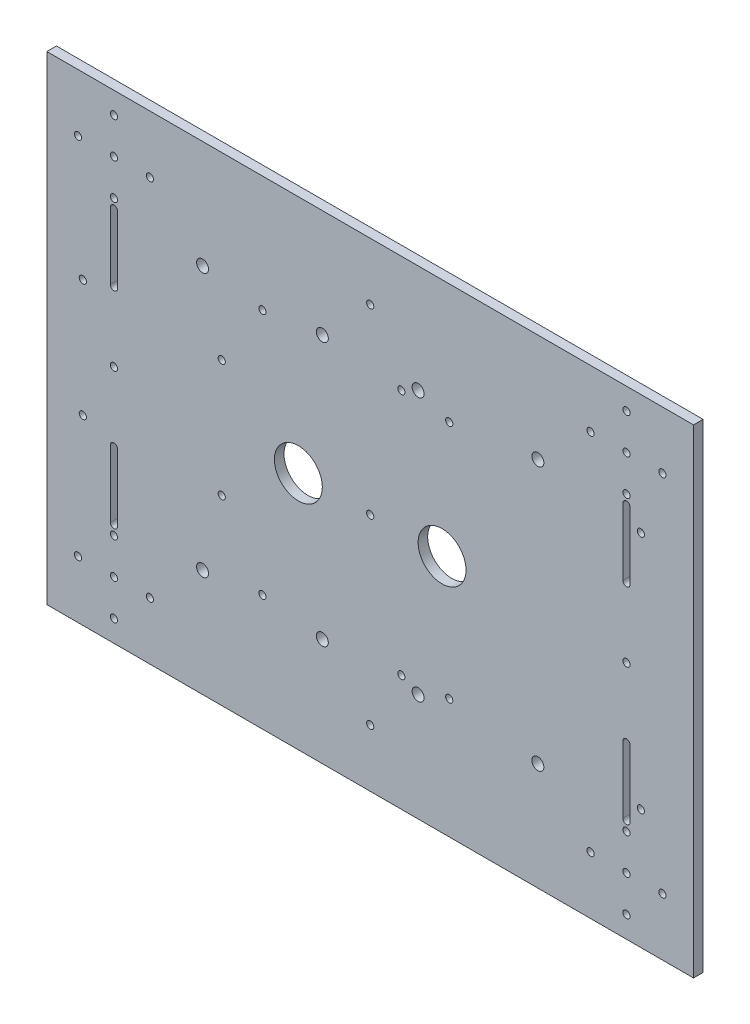
from build123d import *

# Parameters (mm, degrees)
SKETCH1_W           = 270
SKETCH1_H           = 200
SKETCH1_R           = 1.5
SKETCH1_R_2         = 10
SKETCH1_R_3         = 2.5
BOSS_EXTRUDE1_DEPTH = 4


with BuildPart() as part:
    # Sketch1 → Boss-Extrude1 (new body)
    with BuildSketch(Plane.XY):
        with Locations((74.901502586, -16.133333333)):
            Rectangle(SKETCH1_W, SKETCH1_H)
        with Locations((-32.098497414, -92.133333333)):
            Circle(SKETCH1_R, mode=Mode.SUBTRACT)
        with Locations((-17.098497414, -92.133333333)):
            Circle(SKETCH1_R, mode=Mode.SUBTRACT)
        with Locations((-32.098497414, -107.133333333)):
            Circle(SKETCH1_R, mode=Mode.SUBTRACT)
        with Locations((-47.098497414, -92.133333333)):
            Circle(SKETCH1_R, mode=Mode.SUBTRACT)
        with Locations((-32.098497414, -77.133333333)):
            Circle(SKETCH1_R, mode=Mode.SUBTRACT)
        with Locations((74.901502586, -16.133333333)):
            Circle(SKETCH1_R, mode=Mode.SUBTRACT)
        with Locations((196.901502586, -92.133333333)):
            Circle(SKETCH1_R, mode=Mode.SUBTRACT)
        with Locations((181.901502586, -77.133333333)):
            Circle(SKETCH1_R, mode=Mode.SUBTRACT)
        with Locations((181.901502586, -92.133333333)):
            Circle(SKETCH1_R, mode=Mode.SUBTRACT)
        with Locations((181.901502586, -107.133333333)):
            Circle(SKETCH1_R, mode=Mode.SUBTRACT)
        with Locations((166.901502586, -92.133333333)):
            Circle(SKETCH1_R, mode=Mode.SUBTRACT)
        with Locations((196.901502586, 59.866666667)):
            Circle(SKETCH1_R, mode=Mode.SUBTRACT)
        with Locations((181.901502586, 74.866666667)):
            Circle(SKETCH1_R, mode=Mode.SUBTRACT)
        with Locations((181.901502586, 59.866666667)):
            Circle(SKETCH1_R, mode=Mode.SUBTRACT)
        with Locations((181.901502586, 44.866666667)):
            Circle(SKETCH1_R, mode=Mode.SUBTRACT)
        with Locations((166.901502586, 59.866666667)):
            Circle(SKETCH1_R, mode=Mode.SUBTRACT)
        with Locations((-17.098497414, 59.866666667)):
            Circle(SKETCH1_R, mode=Mode.SUBTRACT)
        with Locations((-32.098497414, 74.866666667)):
            Circle(SKETCH1_R, mode=Mode.SUBTRACT)
        with Locations((-32.098497414, 59.866666667)):
            Circle(SKETCH1_R, mode=Mode.SUBTRACT)
        with Locations((-32.098497414, 44.866666667)):
            Circle(SKETCH1_R, mode=Mode.SUBTRACT)
        with Locations((-47.098497414, 59.866666667)):
            Circle(SKETCH1_R, mode=Mode.SUBTRACT)
        with Locations((181.901502586, -16.133333333)):
            Circle(SKETCH1_R, mode=Mode.SUBTRACT)
        with Locations((74.901502586, 59.866666667)):
            Circle(SKETCH1_R, mode=Mode.SUBTRACT)
        with Locations((104.901502586, -16.133333333)):
            Circle(SKETCH1_R_2, mode=Mode.SUBTRACT)
        with Locations((44.901502586, -16.133333333)):
            Circle(SKETCH1_R_2, mode=Mode.SUBTRACT)
        with Locations((-32.098497414, -16.133333333)):
            Circle(SKETCH1_R, mode=Mode.SUBTRACT)
        with Locations((74.901502586, -92.133333333)):
            Circle(SKETCH1_R, mode=Mode.SUBTRACT)
        with Locations((4.901502586, 38.866666667)):
            Circle(SKETCH1_R_3, mode=Mode.SUBTRACT)
        with Locations((54.901502586, 38.866666667)):
            Circle(SKETCH1_R_3, mode=Mode.SUBTRACT)
        with Locations((94.901502586, 38.866666667)):
            Circle(SKETCH1_R_3, mode=Mode.SUBTRACT)
        with Locations((144.901502586, 38.866666667)):
            Circle(SKETCH1_R_3, mode=Mode.SUBTRACT)
        with Locations((94.901502586, -71.133333333)):
            Circle(SKETCH1_R_3, mode=Mode.SUBTRACT)
        with Locations((144.901502586, -71.133333333)):
            Circle(SKETCH1_R_3, mode=Mode.SUBTRACT)
        with Locations((4.901502586, -71.133333333)):
            Circle(SKETCH1_R_3, mode=Mode.SUBTRACT)
        with Locations((54.901502586, -71.133333333)):
            Circle(SKETCH1_R_3, mode=Mode.SUBTRACT)
        with Locations((-45.098497414, 8.866666667)):
            Circle(SKETCH1_R, mode=Mode.SUBTRACT)
        with Locations((12.901502586, 8.866666667)):
            Circle(SKETCH1_R, mode=Mode.SUBTRACT)
        with Locations((12.901502586, -40.133333333)):
            Circle(SKETCH1_R, mode=Mode.SUBTRACT)
        with Locations((-45.098497414, -40.133333333)):
            Circle(SKETCH1_R, mode=Mode.SUBTRACT)
        with Locations((29.901502586, 35.366666667)):
            Circle(SKETCH1_R, mode=Mode.SUBTRACT)
        with Locations((87.901502586, 35.366666667)):
            Circle(SKETCH1_R, mode=Mode.SUBTRACT)
        with Locations((87.901502586, -67.633333333)):
            Circle(SKETCH1_R, mode=Mode.SUBTRACT)
        with Locations((29.901502586, -67.633333333)):
            Circle(SKETCH1_R, mode=Mode.SUBTRACT)
        with Locations((107.901502586, 33.866666667)):
            Circle(SKETCH1_R, mode=Mode.SUBTRACT)
        with Locations((187.901502586, 33.866666667)):
            Circle(SKETCH1_R, mode=Mode.SUBTRACT)
        with Locations((187.901502586, -66.133333333)):
            Circle(SKETCH1_R, mode=Mode.SUBTRACT)
        with Locations((107.901502586, -66.133333333)):
            Circle(SKETCH1_R, mode=Mode.SUBTRACT)
        with BuildLine():
            Line((183.401502586, -45.133333333), (183.401502586, -73.133333333))
            ThreePointArc((183.401502586, -73.133333333), (181.901502586, -74.633333333), (180.401502586, -73.133333333))
            Line((180.401502586, -73.133333333), (180.401502586, -45.133333333))
            ThreePointArc((180.401502586, -45.133333333), (181.901502586, -43.633333333), (183.401502586, -45.133333333))
        make_face(mode=Mode.SUBTRACT)
        with BuildLine():
            Line((-33.598497414, -45.133333333), (-33.598497414, -73.133333333))
            ThreePointArc((-33.598497414, -73.133333333), (-32.098497414, -74.633333333), (-30.598497414, -73.133333333))
            Line((-30.598497414, -73.133333333), (-30.598497414, -45.133333333))
            ThreePointArc((-30.598497414, -45.133333333), (-32.098497414, -43.633333333), (-33.598497414, -45.133333333))
        make_face(mode=Mode.SUBTRACT)
        with BuildLine():
            Line((-33.598497414, 40.866666667), (-33.598497414, 12.866666667))
            ThreePointArc((-33.598497414, 12.866666667), (-32.098497414, 11.366666667), (-30.598497414, 12.866666667))
            Line((-30.598497414, 12.866666667), (-30.598497414, 40.866666667))
            ThreePointArc((-30.598497414, 40.866666667), (-32.098497414, 42.366666667), (-33.598497414, 40.866666667))
        make_face(mode=Mode.SUBTRACT)
        with BuildLine():
            Line((180.401502586, 40.866666667), (180.401502586, 12.866666667))
            ThreePointArc((180.401502586, 12.866666667), (181.901502586, 11.366666667), (183.401502586, 12.866666667))
            Line((183.401502586, 12.866666667), (183.401502586, 40.866666667))
            ThreePointArc((183.401502586, 40.866666667), (181.901502586, 42.366666667), (180.401502586, 40.866666667))
        make_face(mode=Mode.SUBTRACT)
    extrude(amount=BOSS_EXTRUDE1_DEPTH)


solid = part.part
